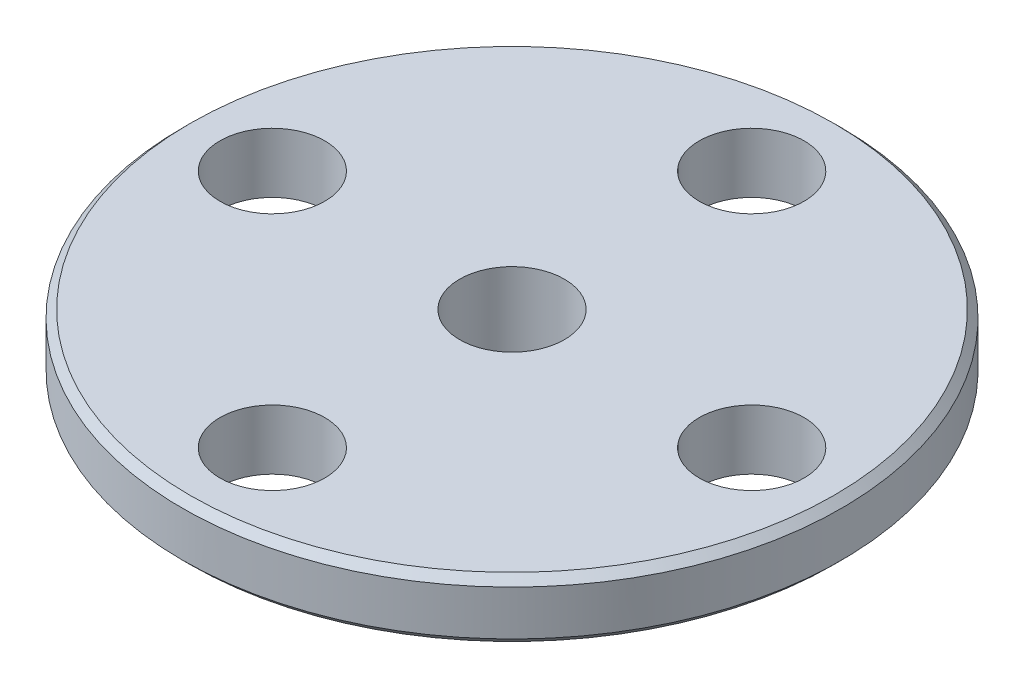
from build123d import *

# Parameters (mm, degrees)
F_3_5_3_5_DIAMETER_HOLE1_D = 3.5
CHAMFER1_SIZE              = 0.25


with BuildPart() as part:
    # Sketch2 → Revolve1 (revolve)
    with BuildSketch(Plane.XY):
        Polygon((-11, 0), (-1.75, 0), (-1.75, -3.2), (-2.85, -3.2), (-2.85, -6.2), (-4.4, -6.2), (-4.4, -2), (-11, -2), align=None)
    revolve(axis=Axis((0, 0, 0), (0, 1, 0)))

    # Ø3.5 (3.5) Diameter Hole1 (through all)
    with Locations(Plane(origin=(0, 0, 0), x_dir=(1, 0, 0), z_dir=(0, 1, 0))):
        with Locations((0, 8), (0, -8), (-8, 0), (8, 0)):
            Hole(F_3_5_3_5_DIAMETER_HOLE1_D / 2)

    # Chamfer1
    chamfer1_edges = [part.edges().sort_by_distance(p)[0] for p in [
        (4.4, -6.2, 0),
        (11, -2, 0),
        (11, 0, 0),
    ]]
    chamfer(chamfer1_edges, length=CHAMFER1_SIZE)


solid = part.part
